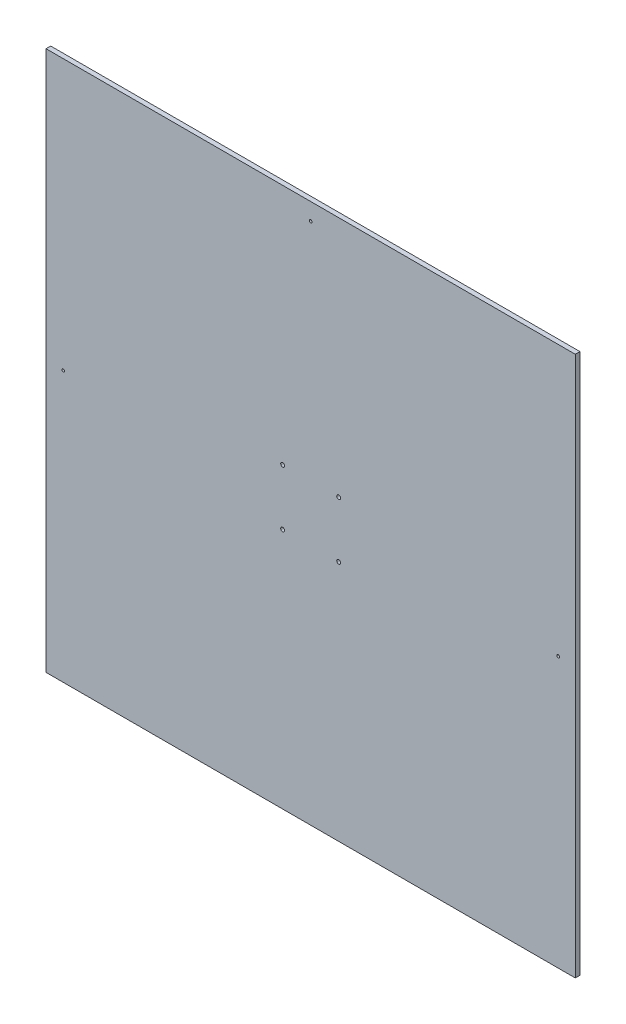
from build123d import *

# Parameters (mm, degrees)
ESQUISSE1_W             = 680
ESQUISSE1_H             = 694
BOSS_EXTRU_1_DEPTH      = 6
ENL_V_MAT_EXTRU_1_REACH = 8
ESQUISSE2_R             = 2.5
ESQUISSE2_R_2           = 1.75


with BuildPart() as part:
    # Esquisse1 → Boss.-Extru.1 (new body)
    with BuildSketch(Plane.XY):
        Rectangle(ESQUISSE1_W, ESQUISSE1_H)
    extrude(amount=BOSS_EXTRU_1_DEPTH)

    # Esquisse2 → Enlèv. mat.-Extru.1 (cut, up to next)
    with BuildSketch(Plane.XY.offset(6), mode=Mode.PRIVATE) as enl_v_mat_extru_1_sk1:
        with Locations((-36, 36)):
            Circle(ESQUISSE2_R)
    enl_v_mat_extru_1_tool1 = extrude(enl_v_mat_extru_1_sk1.sketch, amount=-ENL_V_MAT_EXTRU_1_REACH, mode=Mode.PRIVATE) & part.part
    add(enl_v_mat_extru_1_tool1.solids().sort_by_distance((-36, 36, 6))[0], mode=Mode.SUBTRACT)
    # Esquisse2 → Enlèv. mat.-Extru.1 (cut, up to next)
    with BuildSketch(Plane.XY.offset(6), mode=Mode.PRIVATE) as enl_v_mat_extru_1_sk2:
        with Locations((-36, -36)):
            Circle(ESQUISSE2_R)
    enl_v_mat_extru_1_tool2 = extrude(enl_v_mat_extru_1_sk2.sketch, amount=-ENL_V_MAT_EXTRU_1_REACH, mode=Mode.PRIVATE) & part.part
    add(enl_v_mat_extru_1_tool2.solids().sort_by_distance((-36, -36, 6))[0], mode=Mode.SUBTRACT)
    # Esquisse2 → Enlèv. mat.-Extru.1 (cut, up to next)
    with BuildSketch(Plane.XY.offset(6), mode=Mode.PRIVATE) as enl_v_mat_extru_1_sk3:
        with Locations((36, -36)):
            Circle(ESQUISSE2_R)
    enl_v_mat_extru_1_tool3 = extrude(enl_v_mat_extru_1_sk3.sketch, amount=-ENL_V_MAT_EXTRU_1_REACH, mode=Mode.PRIVATE) & part.part
    add(enl_v_mat_extru_1_tool3.solids().sort_by_distance((36, -36, 6))[0], mode=Mode.SUBTRACT)
    # Esquisse2 → Enlèv. mat.-Extru.1 (cut, up to next)
    with BuildSketch(Plane.XY.offset(6), mode=Mode.PRIVATE) as enl_v_mat_extru_1_sk4:
        with Locations((36, 36)):
            Circle(ESQUISSE2_R)
    enl_v_mat_extru_1_tool4 = extrude(enl_v_mat_extru_1_sk4.sketch, amount=-ENL_V_MAT_EXTRU_1_REACH, mode=Mode.PRIVATE) & part.part
    add(enl_v_mat_extru_1_tool4.solids().sort_by_distance((36, 36, 6))[0], mode=Mode.SUBTRACT)
    # Esquisse2 → Enlèv. mat.-Extru.1 (cut, up to next)
    with BuildSketch(Plane.XY.offset(6), mode=Mode.PRIVATE) as enl_v_mat_extru_1_sk5:
        with Locations((-318, 0)):
            Circle(ESQUISSE2_R_2)
    enl_v_mat_extru_1_tool5 = extrude(enl_v_mat_extru_1_sk5.sketch, amount=-ENL_V_MAT_EXTRU_1_REACH, mode=Mode.PRIVATE) & part.part
    add(enl_v_mat_extru_1_tool5.solids().sort_by_distance((-318, 0, 6))[0], mode=Mode.SUBTRACT)
    # Esquisse2 → Enlèv. mat.-Extru.1 (cut, up to next)
    with BuildSketch(Plane.XY.offset(6), mode=Mode.PRIVATE) as enl_v_mat_extru_1_sk6:
        with Locations((318, 0)):
            Circle(ESQUISSE2_R_2)
    enl_v_mat_extru_1_tool6 = extrude(enl_v_mat_extru_1_sk6.sketch, amount=-ENL_V_MAT_EXTRU_1_REACH, mode=Mode.PRIVATE) & part.part
    add(enl_v_mat_extru_1_tool6.solids().sort_by_distance((318, 0, 6))[0], mode=Mode.SUBTRACT)
    # Esquisse2 → Enlèv. mat.-Extru.1 (cut, up to next)
    with BuildSketch(Plane.XY.offset(6), mode=Mode.PRIVATE) as enl_v_mat_extru_1_sk7:
        with Locations((0, 325)):
            Circle(ESQUISSE2_R_2)
    enl_v_mat_extru_1_tool7 = extrude(enl_v_mat_extru_1_sk7.sketch, amount=-ENL_V_MAT_EXTRU_1_REACH, mode=Mode.PRIVATE) & part.part
    add(enl_v_mat_extru_1_tool7.solids().sort_by_distance((0, 325, 6))[0], mode=Mode.SUBTRACT)


solid = part.part
